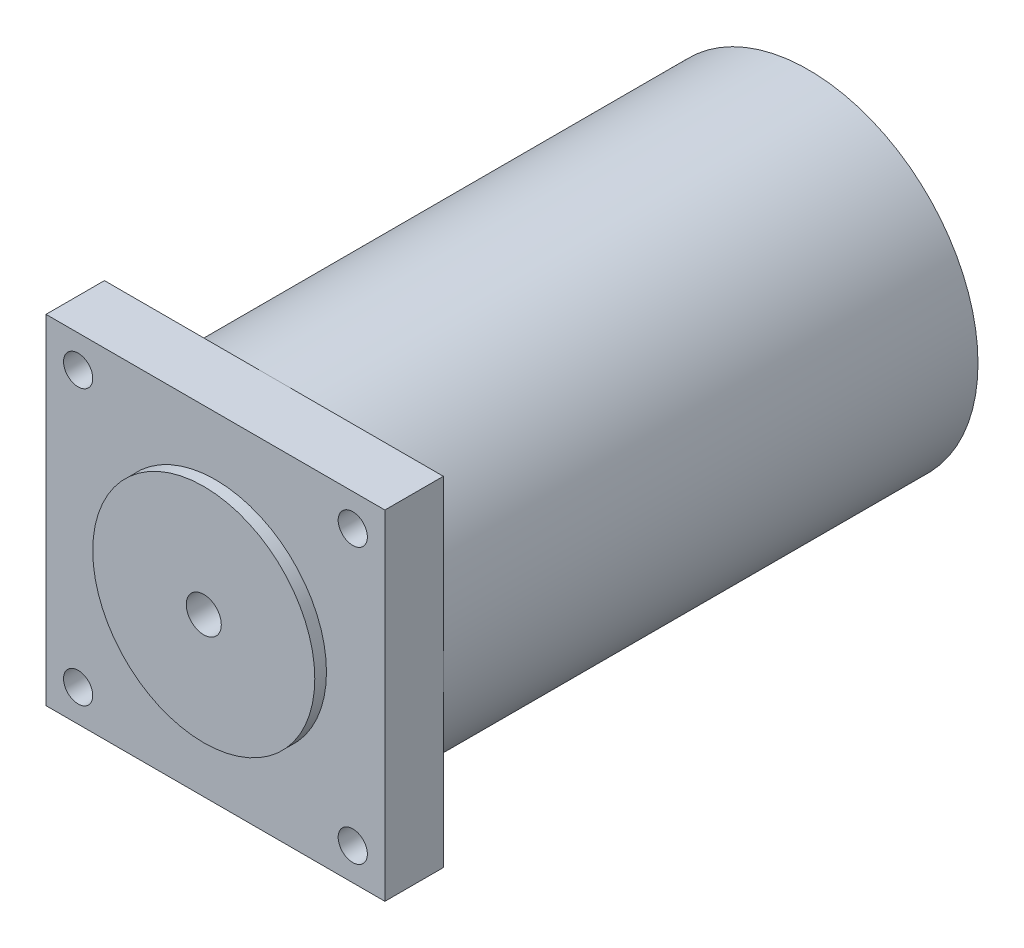
from build123d import *

# Parameters (mm, degrees)
SKETCH1_R           = 19
BOSS_EXTRUDE1_DEPTH = 2
SKETCH3_W           = 58
SKETCH3_H           = 58
BOSS_EXTRUDE2_DEPTH = 10
SKETCH4_R           = 29
BOSS_EXTRUDE3_DEPTH = 91.5
SKETCH5_R           = 2.5
CUT_EXTRUDE1_DEPTH  = 10
SKETCH6_R           = 3
CUT_EXTRUDE2_DEPTH  = 12
SKETCH7_R           = 1.5
CUT_EXTRUDE4_DEPTH  = 30


with BuildPart() as part:
    # Sketch1 → Boss-Extrude1 (new body)
    with BuildSketch(Plane.XY):
        Circle(SKETCH1_R)
    extrude(amount=-BOSS_EXTRUDE1_DEPTH)

    # Sketch3 → Boss-Extrude2 (add)
    with BuildSketch(Plane(origin=(0, 0, -2), x_dir=(-1, 0, 0), z_dir=(0, 0, -1))):
        Rectangle(SKETCH3_W, SKETCH3_H)
    extrude(amount=BOSS_EXTRUDE2_DEPTH)

    # Sketch4 → Boss-Extrude3 (add)
    with BuildSketch(Plane(origin=(0, 0, -12), x_dir=(-1, 0, 0), z_dir=(0, 0, -1))):
        Circle(SKETCH4_R)
    extrude(amount=BOSS_EXTRUDE3_DEPTH)

    # Sketch5 → Cut-Extrude1 (cut)
    with BuildSketch(Plane.XY.offset(-2)):
        with Locations((-23.5, 23.5)):
            Circle(SKETCH5_R)
        with Locations((23.5, 23.5)):
            Circle(SKETCH5_R)
        with Locations((23.5, -23.5)):
            Circle(SKETCH5_R)
        with Locations((-23.5, -23.5)):
            Circle(SKETCH5_R)
    extrude(amount=-CUT_EXTRUDE1_DEPTH, mode=Mode.SUBTRACT)

    # Sketch6 → Cut-Extrude2 (cut)
    with BuildSketch(Plane.XY):
        Circle(SKETCH6_R)
    extrude(amount=-CUT_EXTRUDE2_DEPTH, mode=Mode.SUBTRACT)

    # Sketch7 → Cut-Extrude4 (cut, through all)
    with BuildSketch(Plane(origin=(0, 0, 0), x_dir=(0, 0, -1), z_dir=(1, 0, 0))):
        with Locations((88.5, 0)):
            Circle(SKETCH7_R)
    extrude(amount=-CUT_EXTRUDE4_DEPTH, mode=Mode.SUBTRACT)


solid = part.part
